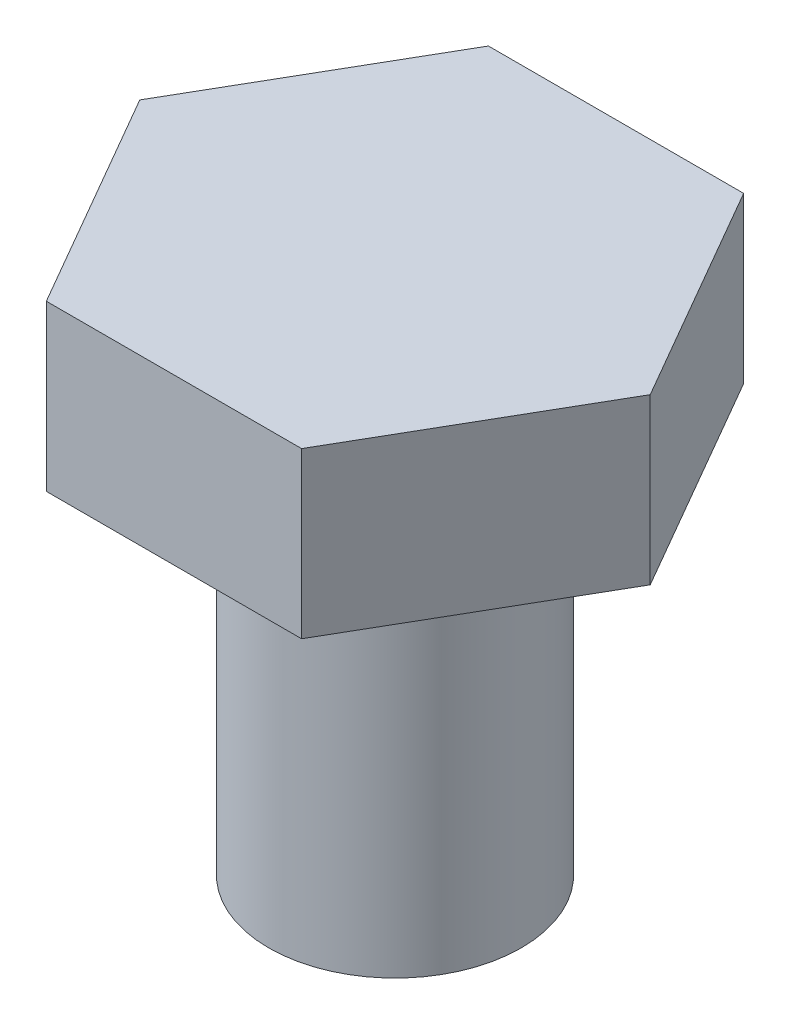
from build123d import *

# Parameters (mm, degrees)
SKETCH1_R           = 3.175
BOSS_EXTRUDE1_DEPTH = 9.525
BOSS_EXTRUDE2_DEPTH = 4.1402


with BuildPart() as part:
    # Sketch1 → Boss-Extrude1 (new body)
    with BuildSketch(Plane(origin=(0, 0, 0), x_dir=(1, 0, 0), z_dir=(0, 1, 0))):
        with Locations(Location((0, 0, 0), (0, 0, 270))):  # turned: the seam where the file's is
            Circle(SKETCH1_R)
    extrude(amount=-BOSS_EXTRUDE1_DEPTH)

    # Sketch2 → Boss-Extrude2 (add)
    with BuildSketch(Plane(origin=(0, 0, 0), x_dir=(1, 0, 0), z_dir=(0, 1, 0))):
        Polygon((-3.207902433, 5.55625), (3.207902433, 5.55625), (6.415804866, 0), (3.207902433, -5.55625), (-3.207902433, -5.55625), (-6.415804866, 0), align=None)
    extrude(amount=BOSS_EXTRUDE2_DEPTH)


solid = part.part
